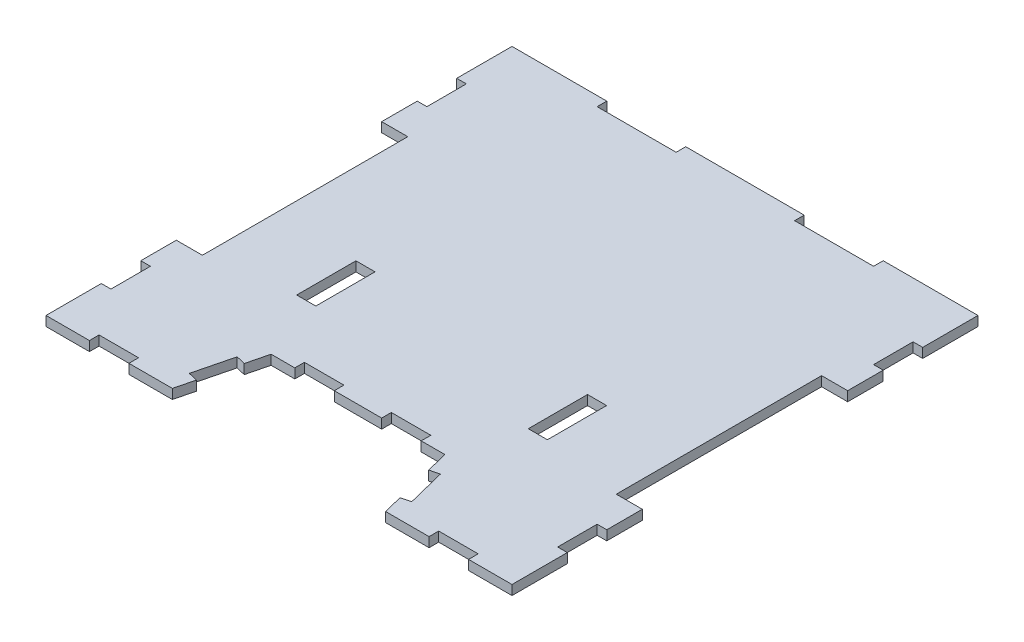
from build123d import *

# Parameters (mm, degrees)
CROQUIS1_W              = 4.84
CROQUIS1_H              = 15
SALIENTE_EXTRUIR1_DEPTH = 2.44


with BuildPart() as part:
    # Croquis1 → Saliente-Extruir1 (new body)
    with BuildSketch(Plane(origin=(0, 0, 0), x_dir=(1, 0, 0), z_dir=(0, 1, 0))):
        Polygon((-59, 45), (-59, 59), (-35, 59), (-35, 56.56), (-15, 56.56), (-15, 59), (15, 59), (15, 56.56), (35, 56.56), (35, 59), (59, 59), (59, 45), (56.56, 45), (56.56, 35), (59, 35), (59, 26), (52.4, 26), (52.4, -26), (59, -26), (59, -35), (56.56, -35), (56.56, -45), (59, -45), (59, -59), (48, -59), (48, -56.56), (38, -56.56), (38, -59), (27, -59), (25.787321875, -54.149287499), (28.154469575, -53.557500574), (25.729113325, -43.856075573), (23.361965624, -44.447862498), (22, -39), (16, -39), (16, -36.56), (6, -36.56), (6, -39), (-6, -39), (-6, -36.56), (-16, -36.56), (-16, -39), (-22, -39), (-23.361965624, -44.447862498), (-25.729113325, -43.856075573), (-28.154469575, -53.557500574), (-25.787321875, -54.149287499), (-27, -59), (-38, -59), (-38, -56.56), (-48, -56.56), (-48, -59), (-59, -59), (-59, -45), (-56.56, -45), (-56.56, -35), (-59, -35), (-59, -26), (-52.4, -26), (-52.4, 26), (-59, 26), (-59, 35), (-56.56, 35), (-56.56, 45), align=None)
        with Locations((29.32, -15.28)):
            Rectangle(CROQUIS1_W, CROQUIS1_H, mode=Mode.SUBTRACT)
        with Locations((-29.32, -15.28)):
            Rectangle(CROQUIS1_W, CROQUIS1_H, mode=Mode.SUBTRACT)
    extrude(amount=SALIENTE_EXTRUIR1_DEPTH)


solid = part.part
